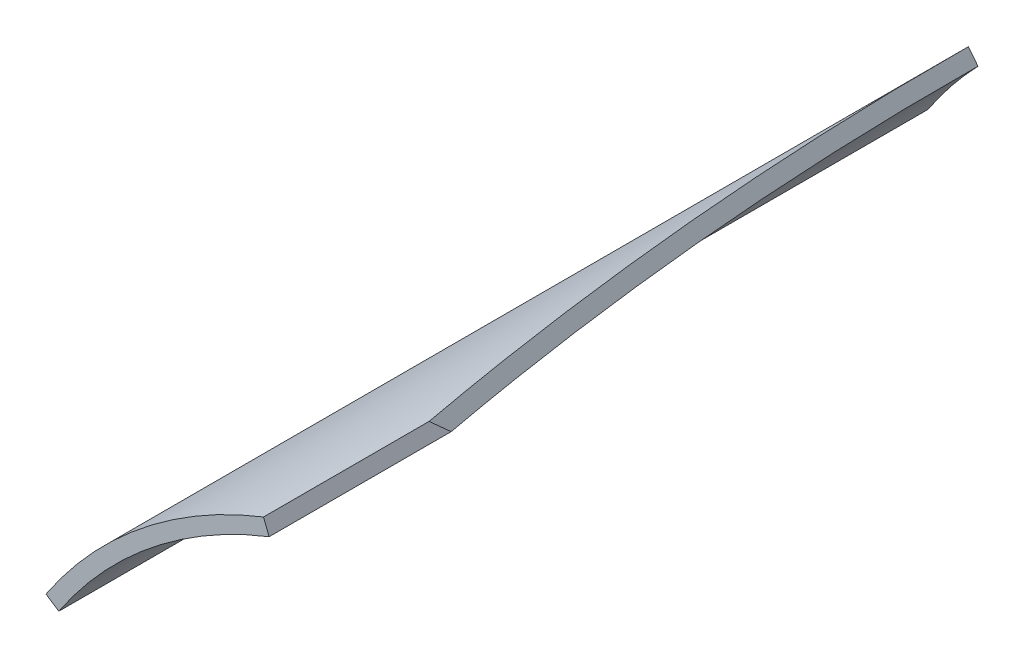
from build123d import *

# Parameters (mm, degrees)
BOSS_EXTRUDE1_START     = -392
BOSS_EXTRUDE1_DEPTH     = 147
CUT_EXTRUDE1_DEPTH      = 148
SKETCH3_OUTSIDE_W       = 81.897
SKETCH3_OUTSIDE_H       = 179.984
CUT_EXTRUDE2_DEPTH      = 26.581353828
CUT_EXTRUDE2_DEPTH_BACK = 23.337511723


with BuildPart() as part:
    # Sketch1 → Boss-Extrude1 (new body)
    with BuildSketch(Plane.XY.offset(BOSS_EXTRUDE1_START)):
        with BuildLine():
            Line((0, 76), (0, 78.6))
            ThreePointArc((0, 78.6), (-78.6, 0), (0, -78.6))
            Line((0, -78.6), (0, -76))
            ThreePointArc((0, -76), (-76, 0), (0, 76))
        make_face()
    extrude(amount=-BOSS_EXTRUDE1_DEPTH)

    # Sketch2 → Cut-Extrude1 (cut, through all)
    with BuildSketch(Plane.XY.offset(-392)):
        with BuildLine():
            Line((0, 0), (-28.679315249, 73.180987127))
            ThreePointArc((-28.679315249, 73.180987127), (49.357896331, -61.169911474), (-65.46760952, 43.496575771))
            Line((-65.46760952, 43.496575771), (0, 0))
        make_face()
    extrude(amount=-CUT_EXTRUDE1_DEPTH, mode=Mode.SUBTRACT)

    # Sketch3 outside → Cut-Extrude2 (cut, two sides)
    with BuildSketch(Plane(origin=(-45.516324952, 56.408999874, 0), x_dir=(0.778243149, 0.627963058, 0), z_dir=(-0.627963058, 0.778243149, 0))) as cut_extrude2_sk:
        with Locations((-0.0825, 465.5)):
            Rectangle(SKETCH3_OUTSIDE_W, SKETCH3_OUTSIDE_H)
        Polygon((23.635475841, 392), (-97.818058366, 392), (-57.320280341, 551.13514832), (-9.635475841, 539), (23.635475841, 420), align=None, mode=Mode.SUBTRACT)
    extrude(amount=CUT_EXTRUDE2_DEPTH, mode=Mode.SUBTRACT)
    extrude(cut_extrude2_sk.sketch, amount=-CUT_EXTRUDE2_DEPTH_BACK, mode=Mode.SUBTRACT)


solid = part.part
